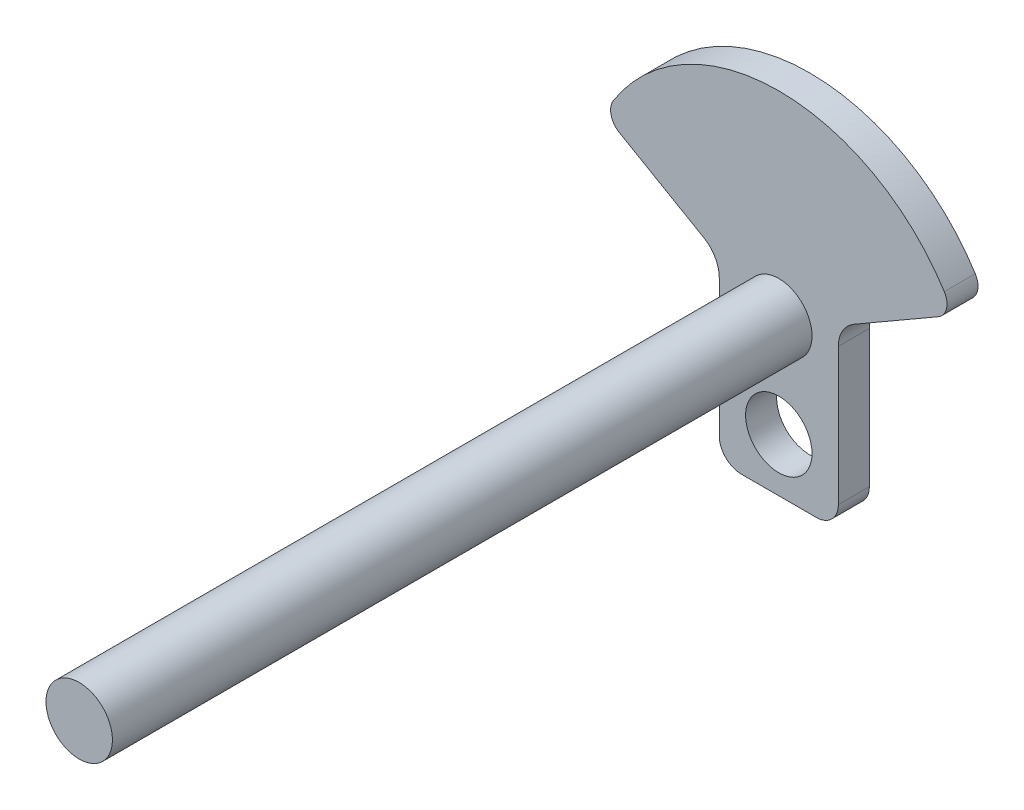
from build123d import *

# Parameters (mm, degrees)
SKETCH2_R           = 7.5
BOSS_EXTRUDE5_DEPTH = 7
SKETCH5_R           = 7.5
BOSS_EXTRUDE6_DEPTH = 165


with BuildPart() as part:
    # Sketch2 → Boss-Extrude5 (new body)
    with BuildSketch(Plane.XY):
        with BuildLine():
            Line((5, 0), (21.89510984, 0))
            ThreePointArc((21.89510984, 0), (25.430643746, 1.464466094), (26.89510984, 5))
            Line((26.89510984, 5), (26.89510984, 35.958548116))
            ThreePointArc((26.89510984, 35.958548116), (27.832932013, 39.458548116), (30.39510984, 42.020725942))
            Line((30.39510984, 42.020725942), (49.440130583, 53.016373795))
            ThreePointArc((49.440130583, 53.016373795), (51.323745621, 55.522595335), (50.821570497, 58.61726368))
            ThreePointArc((50.821570497, 58.61726368), (13.44755492, 79.210770001), (-23.926460657, 58.61726368))
            ThreePointArc((-23.926460657, 58.61726368), (-24.428635781, 55.522595335), (-22.545020743, 53.016373795))
            Line((-22.545020743, 53.016373795), (-3.5, 42.020725942))
            ThreePointArc((-3.5, 42.020725942), (-0.937822174, 39.458548116), (0, 35.958548116))
            Line((0, 35.958548116), (0, 5))
            ThreePointArc((0, 5), (1.464466094, 1.464466094), (5, 0))
        make_face()
        with Locations((13.44755492, 35)):
            Circle(SKETCH2_R, mode=Mode.SUBTRACT)
        with Locations((13.44755492, 12)):
            Circle(SKETCH2_R, mode=Mode.SUBTRACT)
    extrude(amount=BOSS_EXTRUDE5_DEPTH)

    # Sketch5 → Boss-Extrude6 (add)
    with BuildSketch(Plane(origin=(0, 0, 0), x_dir=(-1, 0, 0), z_dir=(0, 0, -1))):
        with Locations((-13.44755492, 35)):
            Circle(SKETCH5_R)
    extrude(amount=-BOSS_EXTRUDE6_DEPTH)


solid = part.part
